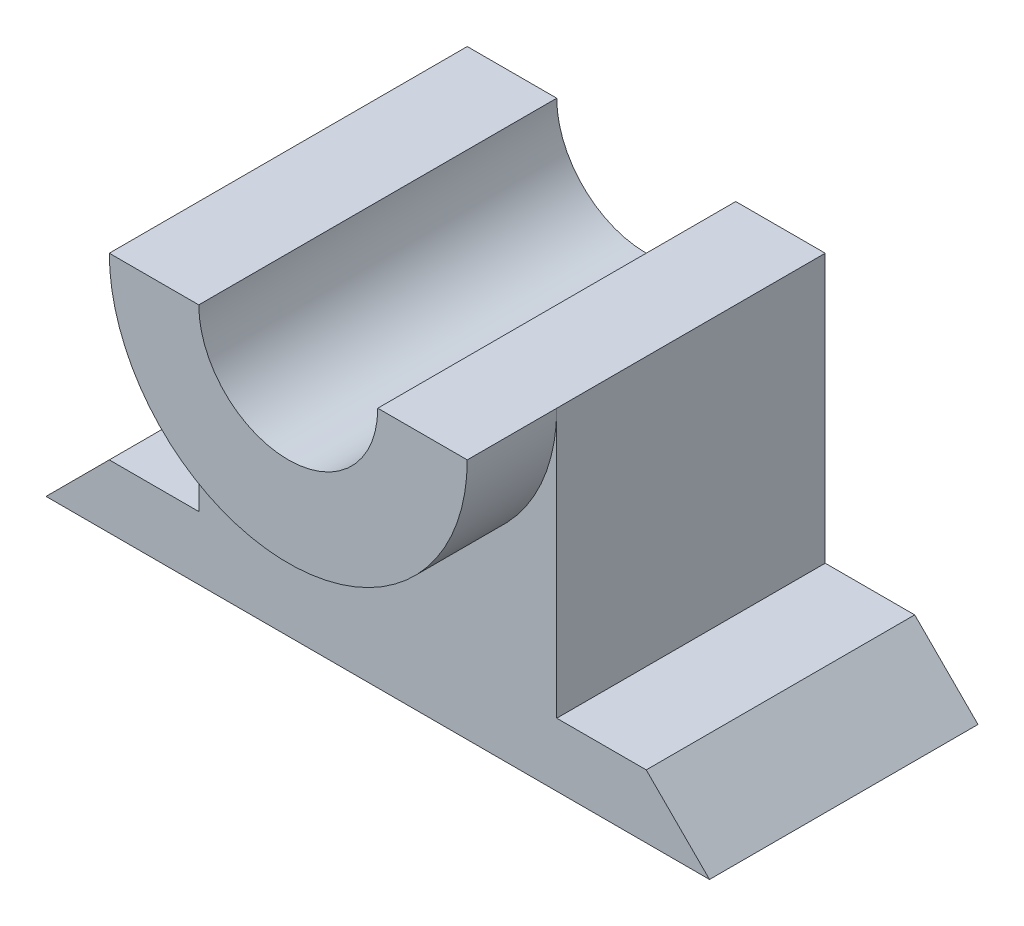
from build123d import *

# Parameters (mm, degrees)
BOSS_EXTRUDE1_DEPTH = 30
BOSS_EXTRUDE2_DEPTH = 40
CUT_EXTRUDE1_DEPTH  = 40


with BuildPart() as part:
    # Sketch1 → Boss-Extrude1 (new body)
    with BuildSketch(Plane.XY):
        Polygon((0, 0), (-10, 0), (-17.071067812, -7.071067812), (57.071067812, -7.071067812), (50, 0), (40, 0), (40, 30), (0, 30), align=None)
    extrude(amount=BOSS_EXTRUDE1_DEPTH)

    # Sketch3 → Boss-Extrude2 (add)
    with BuildSketch(Plane.XY):
        with BuildLine():
            Line((0, 30), (40, 30))
            ThreePointArc((40, 30), (20, 10), (0, 30))
        make_face()
    extrude(amount=BOSS_EXTRUDE2_DEPTH)

    # Sketch4 → Cut-Extrude1 (cut)
    with BuildSketch(Plane.XY.offset(40)):
        with BuildLine():
            Line((10, 30), (30, 30))
            ThreePointArc((30, 30), (20, 20), (10, 30))
        make_face()
    extrude(amount=-CUT_EXTRUDE1_DEPTH, mode=Mode.SUBTRACT)


solid = part.part
